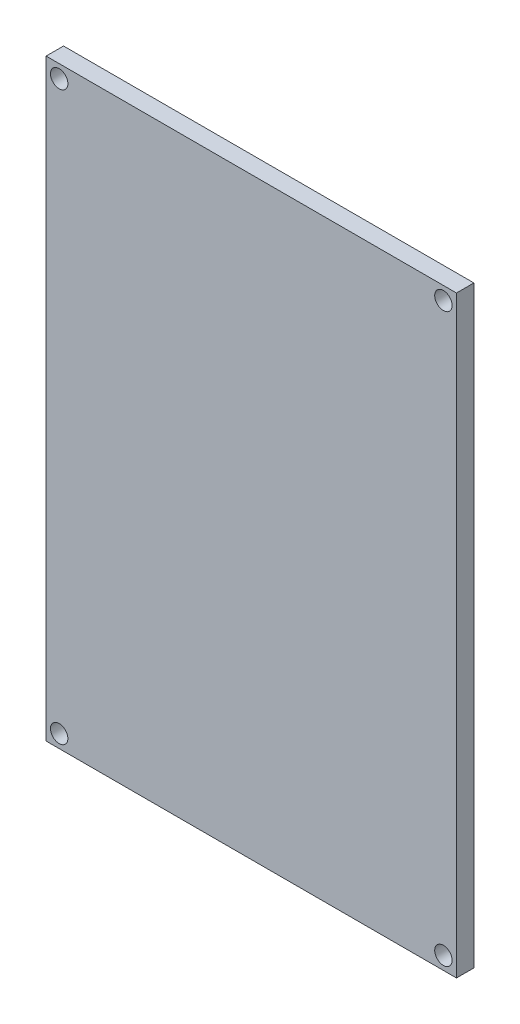
from build123d import *

# Parameters (mm, degrees)
SKETCH1_W           = 70.681980515
SKETCH1_H           = 102.181980515
SKETCH1_R           = 1.5
BOSS_EXTRUDE2_DEPTH = 3
SKETCH1_27_R        = 2.236067977
SKETCH1_27_R_2      = 1.414213562
BOSS_EXTRUDE3_DEPTH = 14.35


with BuildPart() as part:
    # Sketch1 → Boss-Extrude2 (new body)
    with BuildSketch(Plane.XY):
        with Locations((35.340990258, 51.090990258)):
            Rectangle(SKETCH1_W, SKETCH1_H)
        with Locations((2.25, 2.25)):
            Circle(SKETCH1_R, mode=Mode.SUBTRACT)
        with Locations((68.431980515, 2.25)):
            Circle(SKETCH1_R, mode=Mode.SUBTRACT)
        with Locations((2.25, 99.931980515)):
            Circle(SKETCH1_R, mode=Mode.SUBTRACT)
        with Locations((68.431980515, 99.931980515)):
            Circle(SKETCH1_R, mode=Mode.SUBTRACT)
    extrude(amount=BOSS_EXTRUDE2_DEPTH)

    # Sketch1_27 → Boss-Extrude3 (add)
    with BuildSketch(Plane.XY):
        with Locations((22, 72)):
            Circle(SKETCH1_27_R)
        with Locations((35, 21)):
            Circle(SKETCH1_27_R)
        with Locations((50, 73)):
            Circle(SKETCH1_27_R_2)
    extrude(amount=-BOSS_EXTRUDE3_DEPTH)


solid = part.part
